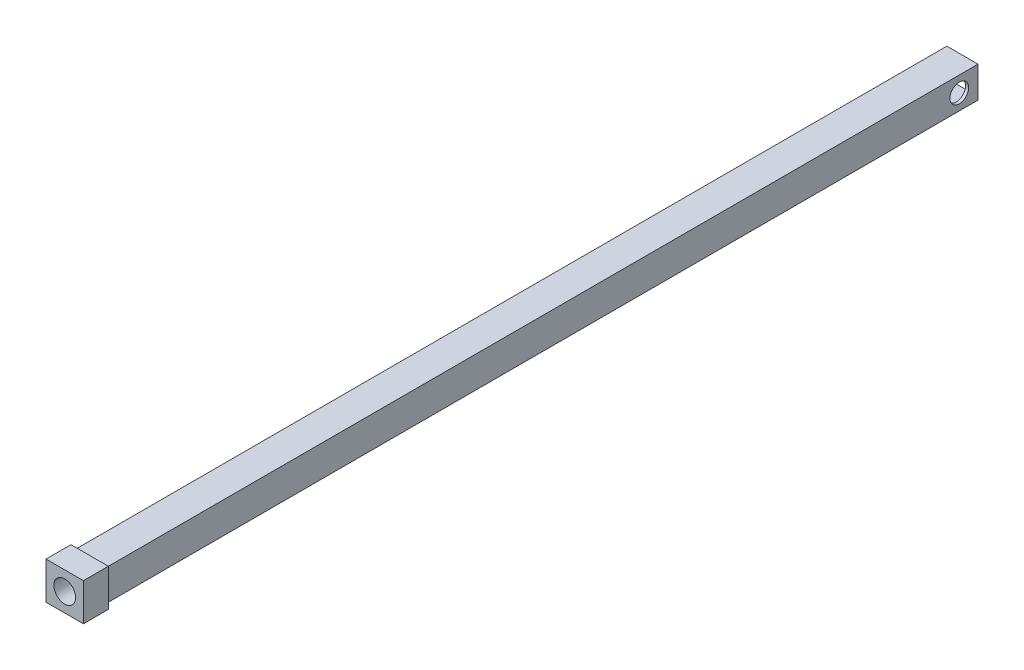
from build123d import *

# Parameters (mm, degrees)
ESQUISSE2_W             = 10
ESQUISSE2_H             = 10
ESQUISSE2_W_2           = 8
ESQUISSE2_H_2           = 8
BOSS_EXTRU_1_DEPTH      = 280
ESQUISSE3_R             = 3
ENL_V_MAT_EXTRU_1_DEPTH = 52
ESQUISSE4_W             = 12
ESQUISSE4_H             = 12
ESQUISSE4_R             = 3.5
BOSS_EXTRU_2_DEPTH      = 8


with BuildPart() as part:
    # Esquisse2 → Boss.-Extru.1 (new body)
    with BuildSketch(Plane.XY):
        Rectangle(ESQUISSE2_W, ESQUISSE2_H)
        Rectangle(ESQUISSE2_W_2, ESQUISSE2_H_2, mode=Mode.SUBTRACT)
    extrude(amount=BOSS_EXTRU_1_DEPTH)

    # Esquisse3 → Enlèv. mat.-Extru.1 (cut)
    with BuildSketch(Plane(origin=(5, 0, 0), x_dir=(0, 0, -1), z_dir=(1, 0, 0))):
        with Locations((-6, 0)):
            Circle(ESQUISSE3_R)
    extrude(amount=-ENL_V_MAT_EXTRU_1_DEPTH, mode=Mode.SUBTRACT)

    # Esquisse4 → Boss.-Extru.2 (add)
    with BuildSketch(Plane.XY.offset(280)):
        Rectangle(ESQUISSE4_W, ESQUISSE4_H)
        Circle(ESQUISSE4_R, mode=Mode.SUBTRACT)
    extrude(amount=BOSS_EXTRU_2_DEPTH)


solid = part.part
